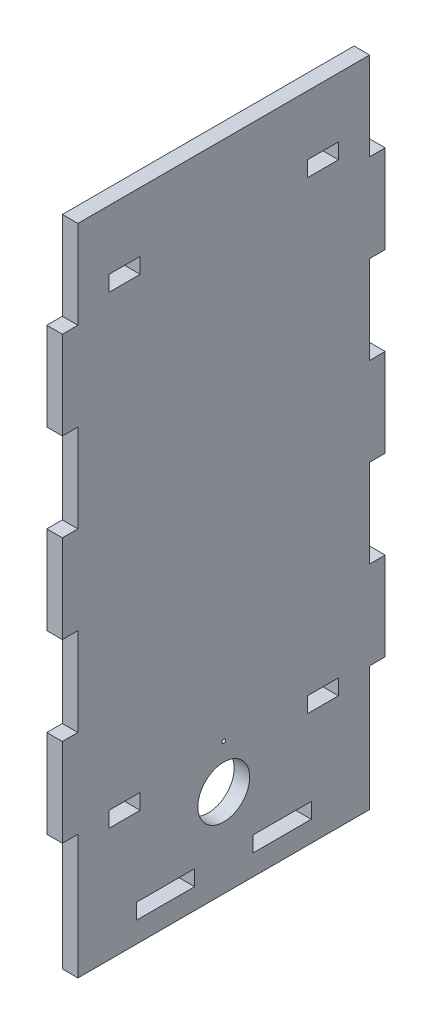
from build123d import *

# Parameters (mm, degrees)
SKETCH1_W           = 112.5
SKETCH1_H           = 238
BOSS_EXTRUDE1_DEPTH = 6
SKETCH2_R           = 10
SKETCH2_R_2         = 0.75
CUT_EXTRUDE1_DEPTH  = 6
SKETCH3_W           = 12
SKETCH3_H           = 6
CUT_EXTRUDE2_DEPTH  = 6
SKETCH4_W           = 6
SKETCH4_H           = 22.5
BOSS_EXTRUDE2_DEPTH = 6
SKETCH5_W           = 12
SKETCH5_H           = 6
CUT_EXTRUDE3_DEPTH  = 6
SKETCH6_W           = 6
SKETCH6_H           = 34
BOSS_EXTRUDE3_DEPTH = 6
SKETCH7_W           = 6
SKETCH7_H           = 112.5
BOSS_EXTRUDE4_DEPTH = 8


with BuildPart() as part:
    # Sketch1 → Boss-Extrude1 (new body)
    with BuildSketch(Plane(origin=(0, 0, 0), x_dir=(0, 0, -1), z_dir=(1, 0, 0))):
        Rectangle(SKETCH1_W, SKETCH1_H)
    extrude(amount=BOSS_EXTRUDE1_DEPTH)

    # Sketch2 → Cut-Extrude1 (cut)
    with BuildSketch(Plane(origin=(6, 0, 0), x_dir=(0, 0, -1), z_dir=(1, 0, 0))):
        with Locations((0, -99)):
            Circle(SKETCH2_R)
        with Locations((0, -82.029437252)):
            Circle(SKETCH2_R_2)
    extrude(amount=-CUT_EXTRUDE1_DEPTH, mode=Mode.SUBTRACT)

    # Sketch3 → Cut-Extrude2 (cut)
    with BuildSketch(Plane(origin=(6, 0, 0), x_dir=(0, 0, -1), z_dir=(1, 0, 0))):
        with Locations((-38.25, -86)):
            Rectangle(SKETCH3_W, SKETCH3_H)
        with Locations((38.25, -86)):
            Rectangle(SKETCH3_W, SKETCH3_H)
    extrude(amount=-CUT_EXTRUDE2_DEPTH, mode=Mode.SUBTRACT)

    # Sketch4 → Boss-Extrude2 (add)
    with BuildSketch(Plane.XZ.offset(119)):
        with Locations((3, -45)):
            Rectangle(SKETCH4_W, SKETCH4_H)
        with Locations((3, 0)):
            Rectangle(SKETCH4_W, SKETCH4_H)
        with Locations((3, 45)):
            Rectangle(SKETCH4_W, SKETCH4_H)
    extrude(amount=BOSS_EXTRUDE2_DEPTH)

    # Sketch5 → Cut-Extrude3 (cut)
    with BuildSketch(Plane(origin=(6, 0, 0), x_dir=(0, 0, -1), z_dir=(1, 0, 0))):
        with Locations((-38.25, 93)):
            Rectangle(SKETCH5_W, SKETCH5_H)
        with Locations((38.25, 93)):
            Rectangle(SKETCH5_W, SKETCH5_H)
    extrude(amount=-CUT_EXTRUDE3_DEPTH, mode=Mode.SUBTRACT)

    # Sketch6 → Boss-Extrude3 (add)
    with BuildSketch(Plane(origin=(0, 0, -56.25), x_dir=(-1, 0, 0), z_dir=(0, 0, -1))):
        with Locations((-3, 68)):
            Rectangle(SKETCH6_W, SKETCH6_H)
        with Locations((-3, 0)):
            Rectangle(SKETCH6_W, SKETCH6_H)
        with Locations((-3, -68)):
            Rectangle(SKETCH6_W, SKETCH6_H)
    boss_extrude3 = extrude(amount=BOSS_EXTRUDE3_DEPTH)

    # Mirror1: Boss-Extrude3 across plane
    add(boss_extrude3.mirror(Plane.XY))

    # Sketch7 → Boss-Extrude4 (add)
    with BuildSketch(Plane(origin=(0, -125, 0), x_dir=(-1, 0, 0), z_dir=(0, -1, 0))):
        with Locations((-3, 0)):
            Rectangle(SKETCH7_W, SKETCH7_H)
    extrude(amount=BOSS_EXTRUDE4_DEPTH)


solid = part.part
